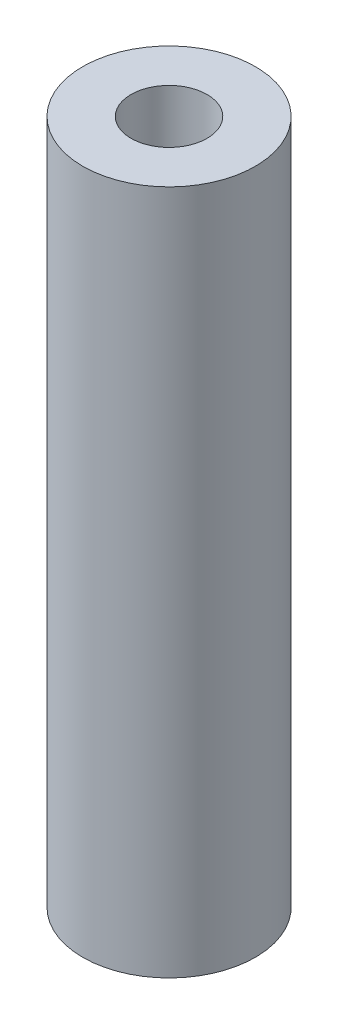
from build123d import *

# Parameters (mm, degrees)
SKETCH1_R                   = 3.2004
BOSS_EXTRUDE1_DEPTH         = 25.4
F_34_0_111_DIAMETER_HOLE1_D = 2.8194


with BuildPart() as part:
    # Sketch1 → Boss-Extrude1 (new body)
    with BuildSketch(Plane(origin=(0, 0, 0), x_dir=(1, 0, 0), z_dir=(0, 1, 0))):
        Circle(SKETCH1_R)
    extrude(amount=BOSS_EXTRUDE1_DEPTH)

    # #34 (0.111) Diameter Hole1 (through all)
    with Locations(Plane(origin=(0, 0, 0), x_dir=(-1, 0, 0), z_dir=(0, -1, 0))):
        with Locations((0, 0)):
            Hole(F_34_0_111_DIAMETER_HOLE1_D / 2)


solid = part.part
